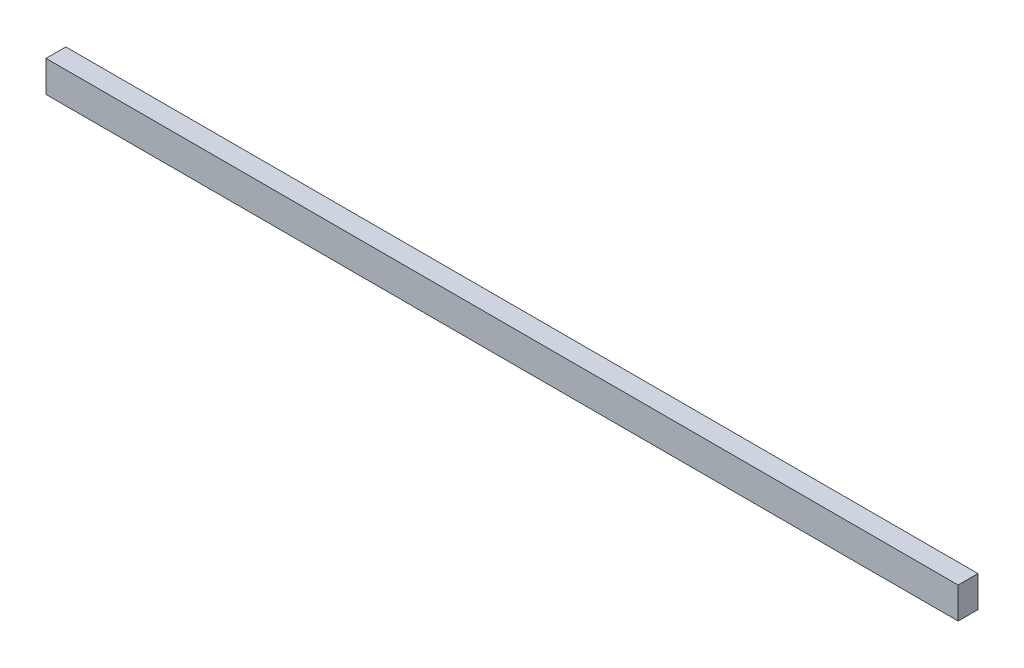
from build123d import *

# Parameters (mm, degrees)
SKETCH1_W           = 292.1
SKETCH1_H           = 10
BOSS_EXTRUDE1_DEPTH = 6.35


with BuildPart() as part:
    # Sketch1 → Boss-Extrude1 (new body)
    with BuildSketch(Plane.XY):
        Rectangle(SKETCH1_W, SKETCH1_H)
    extrude(amount=BOSS_EXTRUDE1_DEPTH)


solid = part.part
